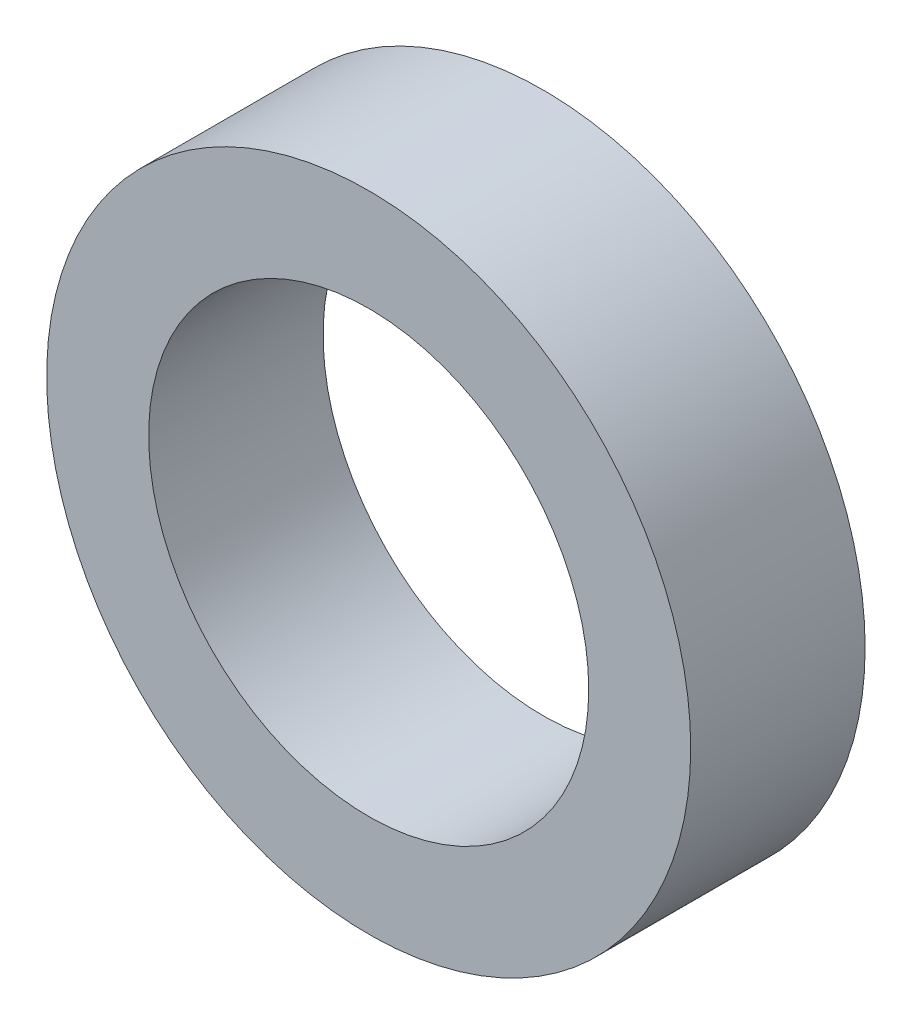
from build123d import *

# Parameters (mm, degrees)
SKETCH1_R           = 6
SKETCH1_R_2         = 4.1
BOSS_EXTRUDE1_DEPTH = 1.625


with BuildPart() as part:
    # Sketch1 → Boss-Extrude1 (new, symmetric)
    with BuildSketch(Plane.XY):
        Circle(SKETCH1_R)
        Circle(SKETCH1_R_2, mode=Mode.SUBTRACT)
    extrude(amount=BOSS_EXTRUDE1_DEPTH, both=True)


solid = part.part
